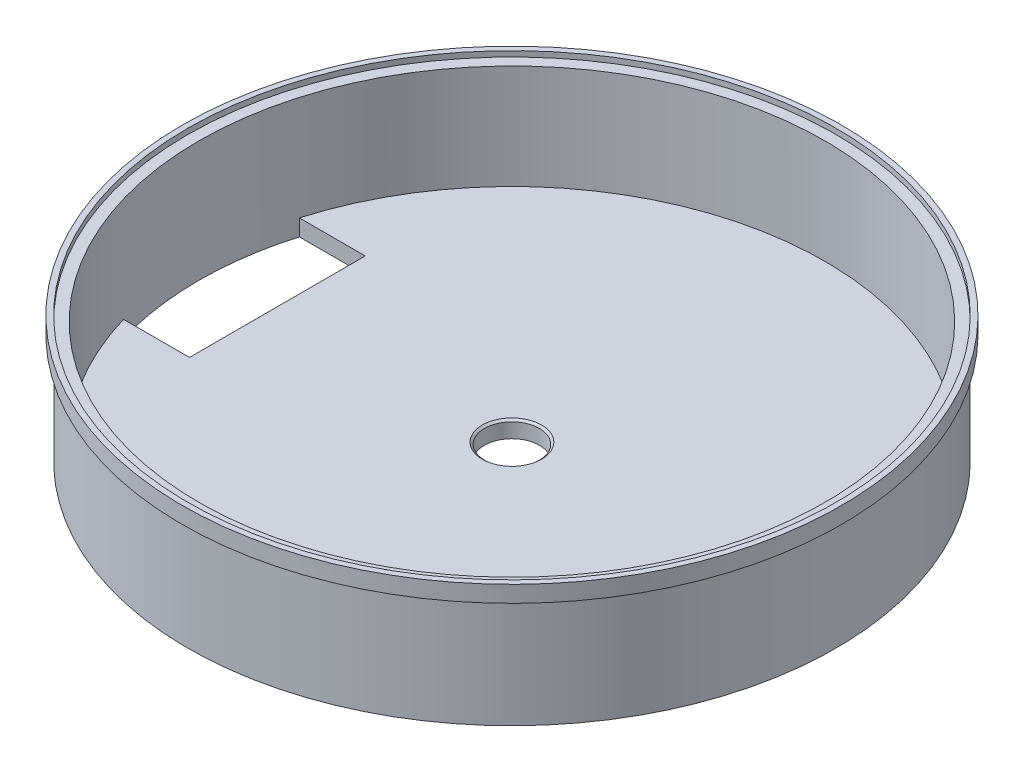
from build123d import *

# Parameters (mm, degrees)
CUT_EXTRUDE1_DEPTH = 25.4


with BuildPart() as part:
    # Sketch1 → Revolve1 (revolve)
    with BuildSketch(Plane.XY):
        Polygon((-95.25, 5.193008475), (-95.25, 0.430508475), (-93.6625, 0.430508475), (-93.6625, -31.319491525), (0, -31.319491525), (0, -26.556991525), (-90.4875, -26.556991525), (-90.4875, 3.605508475), (-93.6625, 3.605508475), (-93.6625, 5.193008475), align=None)
    revolve(axis=Axis((0, 0, 0), (0, -1, 0)))

    # Sketch7 → 5/8 (0.625) Diameter Hole1 (revolve, cut)
    with BuildSketch(Plane(origin=(0, -26.556991525, 0), x_dir=(0, 0, 1), z_dir=(1, 0, 0))):
        Polygon((0, 0), (0, 4.7625), (7.9375, 4.7625), (7.9375, 0.532828266), (8.5725, 0), align=None)
    revolve(axis=Axis((0, -20.206991525, 0), (0, -1, 0)), mode=Mode.SUBTRACT)

    # Sketch12 → Cut-Extrude1 (cut)
    with BuildSketch(Plane(origin=(0, -26.556991525, 0), x_dir=(1, 0, 0), z_dir=(0, 1, 0))):
        with BuildLine():
            Line((-86.849453978, 25.4), (-67.799453978, 25.4))
            Line((-67.799453978, 25.4), (-67.799453978, -25.4))
            Line((-67.799453978, -25.4), (-86.849453978, -25.4))
            ThreePointArc((-86.849453978, -25.4), (-90.4875, 0), (-86.849453978, 25.4))
        make_face()
    extrude(amount=-CUT_EXTRUDE1_DEPTH, mode=Mode.SUBTRACT)


solid = part.part
